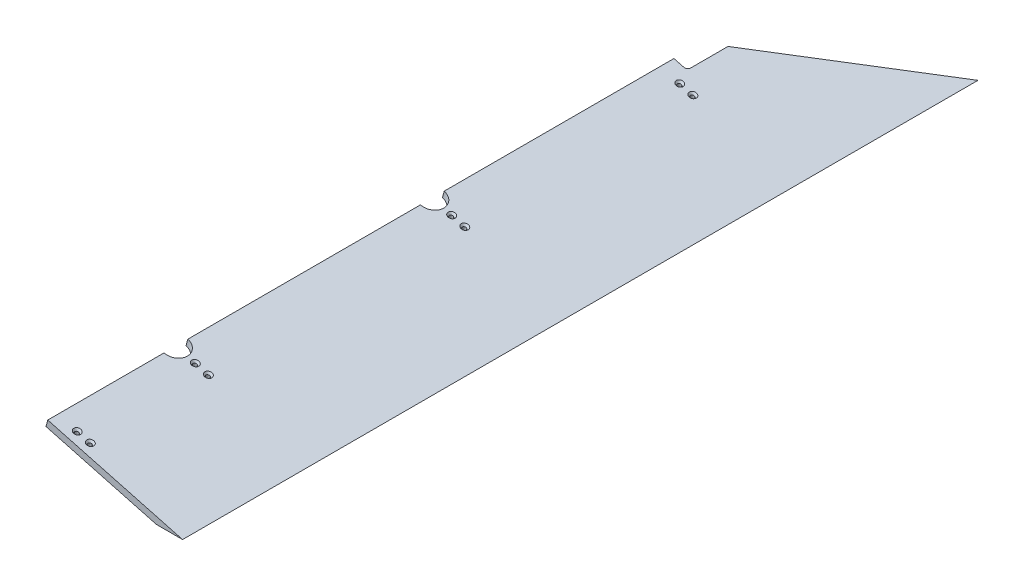
from build123d import *

# Parameters (mm, degrees)
BOSS_EXTRUDE1_DEPTH                                 = 1492.25
CSK_FOR_1_4_FLAT_HEAD_SOCKET_CAP_SCREW1_D           = 7.14248
CSK_FOR_1_4_FLAT_HEAD_SOCKET_CAP_SCREW1_CSINK_D     = 13.4874
CSK_FOR_1_4_FLAT_HEAD_SOCKET_CAP_SCREW1_CSINK_ANGLE = 82
SKETCH4_R                                           = 22.225
CUT_EXTRUDE1_DEPTH                                  = 67.312434508
CUT_EXTRUDE2_DEPTH                                  = 67.312434508
FILLET1_R                                           = 6.35


with BuildPart() as part:
    # Sketch1 → Boss-Extrude1 (new body)
    with BuildSketch(Plane.XY):
        Polygon((22.225, 55.50367642), (229.367540407, 0), (278.436572382, 0), (25.512001873, 67.770934414), align=None)
    extrude(amount=BOSS_EXTRUDE1_DEPTH)

    # CSK for 1/4 Flat Head Socket Cap Screw1 (through all)
    with Locations(Plane(origin=(18.651713678, 69.609143096, 0), x_dir=(0.965925826, -0.258819045, 0), z_dir=(0.258819045, 0.965925826, 0))):
        with Locations((44.668892959, -1251.74375), (70.068892959, -1251.74375), (44.668892959, -770.73125), (70.068892959, -770.73125), (44.668892959, -1473.2), (70.068892959, -1473.2), (44.668892959, -342.9), (70.068892959, -342.9)):
            CounterSinkHole(CSK_FOR_1_4_FLAT_HEAD_SOCKET_CAP_SCREW1_D / 2, CSK_FOR_1_4_FLAT_HEAD_SOCKET_CAP_SCREW1_CSINK_D / 2, counter_sink_angle=CSK_FOR_1_4_FLAT_HEAD_SOCKET_CAP_SCREW1_CSINK_ANGLE)

    # Sketch4 → Cut-Extrude1 (cut, through all)
    with BuildSketch(Plane(origin=(18.651713678, 69.609143096, 0), x_dir=(0.965925826, -0.258819045, 0), z_dir=(0.258819045, 0.965925826, 0))):
        with Locations((7.102292959, -770.73125)):
            Circle(SKETCH4_R)
        with Locations((7.102292959, -1251.74375)):
            Circle(SKETCH4_R)
    extrude(amount=-CUT_EXTRUDE1_DEPTH, mode=Mode.SUBTRACT)

    # Sketch5 → Cut-Extrude2 (cut, through all)
    with BuildSketch(Plane(origin=(18.651713678, 69.609143096, 0), x_dir=(0.965925826, -0.258819045, 0), z_dir=(0.258819045, 0.965925826, 0))):
        Polygon((7.102292959, -317.5), (7.102292959, 0), (268.949076248, 0), (32.502292959, -240.609994719), (32.502292959, -317.5), align=None)
    extrude(amount=-CUT_EXTRUDE2_DEPTH, mode=Mode.SUBTRACT)

    # Fillet1
    fillet1_edges = [part.edges().sort_by_distance(p)[0] for p in [
        (48.403016924, 55.063301672, 317.5),
    ]]
    fillet(fillet1_edges, radius=FILLET1_R)


solid = part.part
